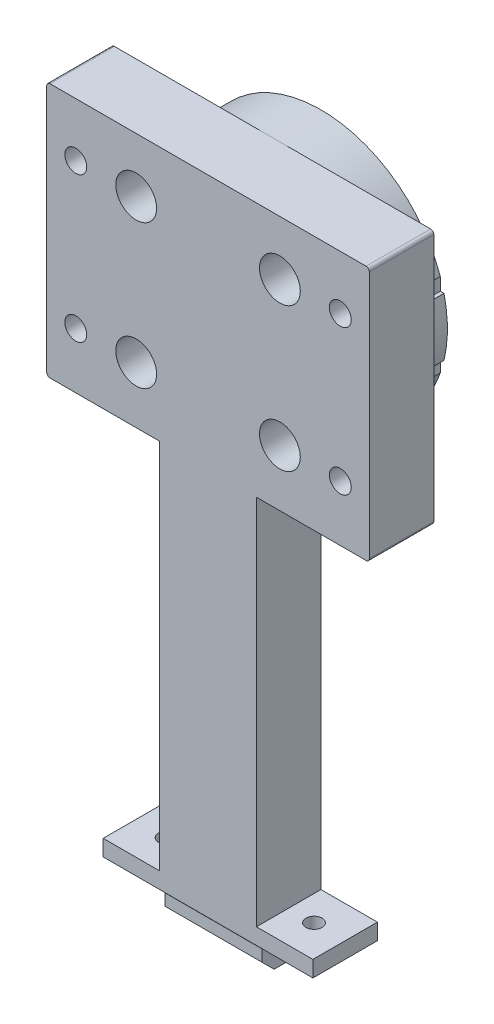
from build123d import *

# Parameters (mm, degrees)
ESTRUSIONE_ESTRUSIONE2_DEPTH      = 1
ESTRUSIONE_ESTRUSIONE2_2_DEPTH    = 1
ESTRUSIONE_ESTRUSIONE3_DEPTH      = 15
SCHIZZO4_W                        = 100
SCHIZZO4_H                        = 79
ESTRUSIONE_ESTRUSIONE4_DEPTH      = 20
TAGLIO_ESTRUSIONE2_DEPTH          = 36
RACCORDO1_R                       = 1
ESTRUSIONE_ESTRUSIONE5_DEPTH      = 20
ESTRUSIONE_ESTRUSIONE6_DEPTH      = 30
SCHIZZO11_W                       = 20
SCHIZZO11_H                       = 5
ESTRUSIONE_ESTRUSIONE7_DEPTH      = 17.5
ESTRUSIONE_ESTRUSIONE7_DEPTH_BACK = 47.5
TAGLIO_ESTRUSIONE5_REACH          = 201.338
SCHIZZO13_R                       = 2.5
SCHIZZO14_R                       = 6.3235
SCHIZZO14_R_2                     = 3.3235
TAGLIO_ESTRUSIONE6_DEPTH          = 10
TAGLIO_ESTRUSIONE7_DEPTH          = 20
SCHIZZO7_R                        = 6
TAGLIO_ESTRUSIONE4_DEPTH          = 8


with BuildPart() as part:
    # Schizzo1 → Estrusione-Estrusione2 (new body)
    with BuildSketch(Plane.XY):
        with BuildLine():
            ThreePointArc((-1482, 0), (-1485, 3), (-1488, 0))
            ThreePointArc((-1488, 0), (-1485, -3), (-1482, 0))
        make_face()
    extrude(amount=-ESTRUSIONE_ESTRUSIONE2_DEPTH)



with BuildPart() as body_2:
    # Schizzo1 → Estrusione-Estrusione2 2 (new body)
    with BuildSketch(Plane.XY):
        with BuildLine():
            ThreePointArc((-1475.75, 0), (-1460, -15.75), (-1444.25, 0))
            ThreePointArc((-1444.25, 0), (-1460, 15.75), (-1475.75, 0))
        make_face()
    extrude(amount=-ESTRUSIONE_ESTRUSIONE2_2_DEPTH)


with BuildPart() as part_1:
    add(part.part)

    add(body_2.part)  # Estrusione-Estrusione3 merges body 2
    # Schizzo2 → Estrusione-Estrusione3 (add)
    with BuildSketch(Plane.XY):
        with BuildLine():
            Line((-1423, 14.138214937), (-1423, 18.085801585))
            add(Edge.make_bspline(
                [(-1423, 18.085801585), (-1424.815922694, 23.27497966), (-1427.541323769, 28.145982802), (-1431.102851615, 32.485450033), (-1439.594271418, 39.731973592), (-1450.044163239, 43.658327797), (-1455.564993498, 44.676158034), (-1466.7280127, 44.734359641), (-1477.245308948, 40.992328412), (-1482.120117986, 38.208118184), (-1490.68666297, 31.050559385), (-1496.308059, 21.406065909), (-1498.236323874, 16.133743979), (-1500.163676126, 5.138214937), (-1498.236323874, -5.857314104), (-1496.308059, -11.129636034), (-1490.68666297, -20.774129511), (-1482.120117986, -27.931688309), (-1477.245308948, -30.715898537), (-1466.7280127, -34.457929766), (-1455.564993498, -34.399728159), (-1450.044163239, -33.381897922), (-1439.594271418, -29.455543717), (-1431.102851615, -22.209020158), (-1427.541323769, -17.869552928), (-1424.815922694, -12.998549785), (-1422.999999932, -7.809371515)],
                knots=[-1.234179621, -1.234179621, -1.234179621, -1.234179621, -1.234179621, -1.234179621, -0.532935634, -0.532935634, -0.532935634, 0.168308353, 0.168308353, 0.168308353, 0.86955234, 0.86955234, 0.86955234, 1.570796327, 1.570796327, 1.570796327, 2.272040314, 2.272040314, 2.272040314, 2.973284301, 2.973284301, 2.973284301, 3.674528288, 3.674528288, 3.674528288, 4.375772275, 4.375772275, 4.375772275, 4.375772275, 4.375772275, 4.375772275], degree=5))
            Line((-1422.999999932, -7.809371515), (-1423, -3.861785063))
            Line((-1423, -3.861785063), (-1421.847149517, -3.861785063))
            ThreePointArc((-1421.847149517, -3.861785063), (-1420.8, 5.138214937), (-1421.847149517, 14.138214937))
            Line((-1421.847149517, 14.138214937), (-1423, 14.138214937))
        make_face()
        with BuildLine():
            ThreePointArc((-1437.726136393, 30.735578545), (-1441.049636393, 27.412078545), (-1437.726136393, 24.088578545))
            ThreePointArc((-1437.726136393, 24.088578545), (-1434.402636393, 27.412078545), (-1437.726136393, 30.735578545))
        make_face(mode=Mode.SUBTRACT)
        with BuildLine():
            ThreePointArc((-1437.726136393, -13.81214867), (-1441.049636393, -17.13564867), (-1437.726136393, -20.45914867))
            ThreePointArc((-1437.726136393, -20.45914867), (-1434.402636393, -17.13564867), (-1437.726136393, -13.81214867))
        make_face(mode=Mode.SUBTRACT)
        with BuildLine():
            ThreePointArc((-1482.273863607, -13.81214867), (-1485.597363607, -17.13564867), (-1482.273863607, -20.45914867))
            ThreePointArc((-1482.273863607, -20.45914867), (-1478.950363607, -17.13564867), (-1482.273863607, -13.81214867))
        make_face(mode=Mode.SUBTRACT)
        with BuildLine():
            ThreePointArc((-1482.273863607, 30.735578545), (-1485.597363607, 27.412078545), (-1482.273863607, 24.088578545))
            ThreePointArc((-1482.273863607, 24.088578545), (-1478.950363607, 27.412078545), (-1482.273863607, 30.735578545))
        make_face(mode=Mode.SUBTRACT)
    extrude(amount=ESTRUSIONE_ESTRUSIONE3_DEPTH)

    # Schizzo4 → Estrusione-Estrusione4 (add)
    with BuildSketch(Plane.XY.offset(15)):
        with Locations((-1460, 4.838223987)):
            Rectangle(SCHIZZO4_W, SCHIZZO4_H)
    extrude(amount=ESTRUSIONE_ESTRUSIONE4_DEPTH)

    # Schizzo5 → Taglio-Estrusione2 (cut)
    with BuildSketch(Plane(origin=(0, 0, -1), x_dir=(-1, 0, 0), z_dir=(0, 0, -1))):
        with BuildLine():
            ThreePointArc((1437.726136393, -13.81214867), (1434.402636393, -17.13564867), (1437.726136393, -20.45914867))
            ThreePointArc((1437.726136393, -20.45914867), (1441.049636393, -17.13564867), (1437.726136393, -13.81214867))
        make_face()
        with BuildLine():
            ThreePointArc((1437.726136393, 24.088578545), (1441.049636393, 27.412078545), (1437.726136393, 30.735578545))
            ThreePointArc((1437.726136393, 30.735578545), (1434.402636393, 27.412078545), (1437.726136393, 24.088578545))
        make_face()
        with BuildLine():
            ThreePointArc((1482.273863607, 24.088578545), (1485.597363607, 27.412078545), (1482.273863607, 30.735578545))
            ThreePointArc((1482.273863607, 30.735578545), (1478.950363607, 27.412078545), (1482.273863607, 24.088578545))
        make_face()
        with BuildLine():
            ThreePointArc((1482.273863607, -20.45914867), (1485.597363607, -17.13564867), (1482.273863607, -13.81214867))
            ThreePointArc((1482.273863607, -13.81214867), (1478.950363607, -17.13564867), (1482.273863607, -20.45914867))
        make_face()
    extrude(amount=-TAGLIO_ESTRUSIONE2_DEPTH, mode=Mode.SUBTRACT)

    # Raccordo1
    raccordo1_edges = [part_1.edges().sort_by_distance(p)[0] for p in [
        (-1510, -34.661776013, 25),
        (-1510, 44.338223987, 25),
        (-1410, -34.661776013, 25),
        (-1410, 44.338223987, 25),
    ]]
    fillet(raccordo1_edges, radius=RACCORDO1_R)

    # Schizzo8 → Estrusione-Estrusione5 (add)
    with BuildSketch(Plane.XY.offset(35)):
        Polygon((-1460, -34.661776013), (-1475, -34.661776013), (-1475, -155), (-1465.76, -155), (-1445, -155), (-1445, -34.661776013), align=None)
    extrude(amount=-ESTRUSIONE_ESTRUSIONE5_DEPTH)

    # Schizzo10 → Estrusione-Estrusione6 (add)
    with BuildSketch(Plane.ZY.offset(1475)):
        Polygon((20.7, -155), (20.7, -156.76), (16.7, -156.76), (16.7, -160.36), (20.483021279, -164.143021279), (29.516978721, -164.143021279), (33.3, -160.36), (33.3, -156.76), (29.3, -156.76), (29.3, -155), align=None)
    extrude(amount=-ESTRUSIONE_ESTRUSIONE6_DEPTH)

    # Schizzo11 → Estrusione-Estrusione7 (add, two sides)
    with BuildSketch(Plane(origin=(-1445, 0, 0), x_dir=(0, 0, -1), z_dir=(1, 0, 0))) as estrusione_estrusione7_sk:
        with Locations((-25, -152.5)):
            Rectangle(SCHIZZO11_W, SCHIZZO11_H)
    extrude(amount=ESTRUSIONE_ESTRUSIONE7_DEPTH)
    extrude(estrusione_estrusione7_sk.sketch, amount=-ESTRUSIONE_ESTRUSIONE7_DEPTH_BACK)

    # Schizzo13 → Taglio-Estrusione5 (cut, up to next)
    with BuildSketch(Plane.XZ.offset(155), mode=Mode.PRIVATE) as taglio_estrusione5_sk1:
        with Locations((-1437.15, 25)):
            Circle(SCHIZZO13_R)
    taglio_estrusione5_tool1 = extrude(taglio_estrusione5_sk1.sketch, amount=-TAGLIO_ESTRUSIONE5_REACH, mode=Mode.PRIVATE) & part_1.part
    add(taglio_estrusione5_tool1.solids().sort_by_distance((-1437.15, -155, 25))[0], mode=Mode.SUBTRACT)
    # Schizzo13 → Taglio-Estrusione5 (cut, up to next)
    with BuildSketch(Plane.XZ.offset(155), mode=Mode.PRIVATE) as taglio_estrusione5_sk2:
        with Locations((-1482.85, 25)):
            Circle(SCHIZZO13_R)
    taglio_estrusione5_tool2 = extrude(taglio_estrusione5_sk2.sketch, amount=-TAGLIO_ESTRUSIONE5_REACH, mode=Mode.PRIVATE) & part_1.part
    add(taglio_estrusione5_tool2.solids().sort_by_distance((-1482.85, -155, 25))[0], mode=Mode.SUBTRACT)

    # Schizzo14 → Taglio-Estrusione6 (cut)
    with BuildSketch(Plane.XY.offset(35)):
        with Locations((-1482.273863607, 27.412078545)):
            Circle(SCHIZZO14_R)
        with Locations((-1482.273863607, 27.412078545)):
            Circle(SCHIZZO14_R_2, mode=Mode.SUBTRACT)
        with Locations((-1482.273863607, -17.13564867)):
            Circle(SCHIZZO14_R)
        with Locations((-1482.273863607, -17.13564867)):
            Circle(SCHIZZO14_R_2, mode=Mode.SUBTRACT)
        with Locations((-1437.726136393, -17.13564867)):
            Circle(SCHIZZO14_R)
        with Locations((-1437.726136393, -17.13564867)):
            Circle(SCHIZZO14_R_2, mode=Mode.SUBTRACT)
        with Locations((-1437.726136393, 27.412078545)):
            Circle(SCHIZZO14_R)
        with Locations((-1437.726136393, 27.412078545)):
            Circle(SCHIZZO14_R_2, mode=Mode.SUBTRACT)
    extrude(amount=-TAGLIO_ESTRUSIONE6_DEPTH, mode=Mode.SUBTRACT)

    # Schizzo15 → Taglio-Estrusione7 (cut)
    with BuildSketch(Plane.XY.offset(35)):
        with BuildLine():
            ThreePointArc((-1419, 24.238214937), (-1415.6, 27.638214937), (-1419, 31.038214937))
            ThreePointArc((-1419, 31.038214937), (-1422.4, 27.638214937), (-1419, 24.238214937))
        make_face()
        with BuildLine():
            ThreePointArc((-1419, -13.961785063), (-1422.4, -17.361785063), (-1419, -20.761785063))
            ThreePointArc((-1419, -20.761785063), (-1415.6, -17.361785063), (-1419, -13.961785063))
        make_face()
        with BuildLine():
            ThreePointArc((-1501, -13.961785063), (-1504.4, -17.361785063), (-1501, -20.761785063))
            ThreePointArc((-1501, -20.761785063), (-1497.6, -17.361785063), (-1501, -13.961785063))
        make_face()
        with BuildLine():
            ThreePointArc((-1501, 31.038214937), (-1504.4, 27.638214937), (-1501, 24.238214937))
            ThreePointArc((-1501, 24.238214937), (-1497.6, 27.638214937), (-1501, 31.038214937))
        make_face()
    extrude(amount=-TAGLIO_ESTRUSIONE7_DEPTH, mode=Mode.SUBTRACT)

    # Schizzo7 → Taglio-Estrusione4 (cut)
    with BuildSketch(Plane(origin=(0, 0, 15), x_dir=(-1, 0, 0), z_dir=(0, 0, -1))):
        with Locations((1419, 27.638214937)):
            Circle(SCHIZZO7_R)
        with Locations((1501, -17.361785063)):
            Circle(SCHIZZO7_R)
        with Locations((1501, 27.638214937)):
            Circle(SCHIZZO7_R)
        with Locations((1419, -17.361785063)):
            Circle(SCHIZZO7_R)
    extrude(amount=-TAGLIO_ESTRUSIONE4_DEPTH, mode=Mode.SUBTRACT)


solid = part_1.part
